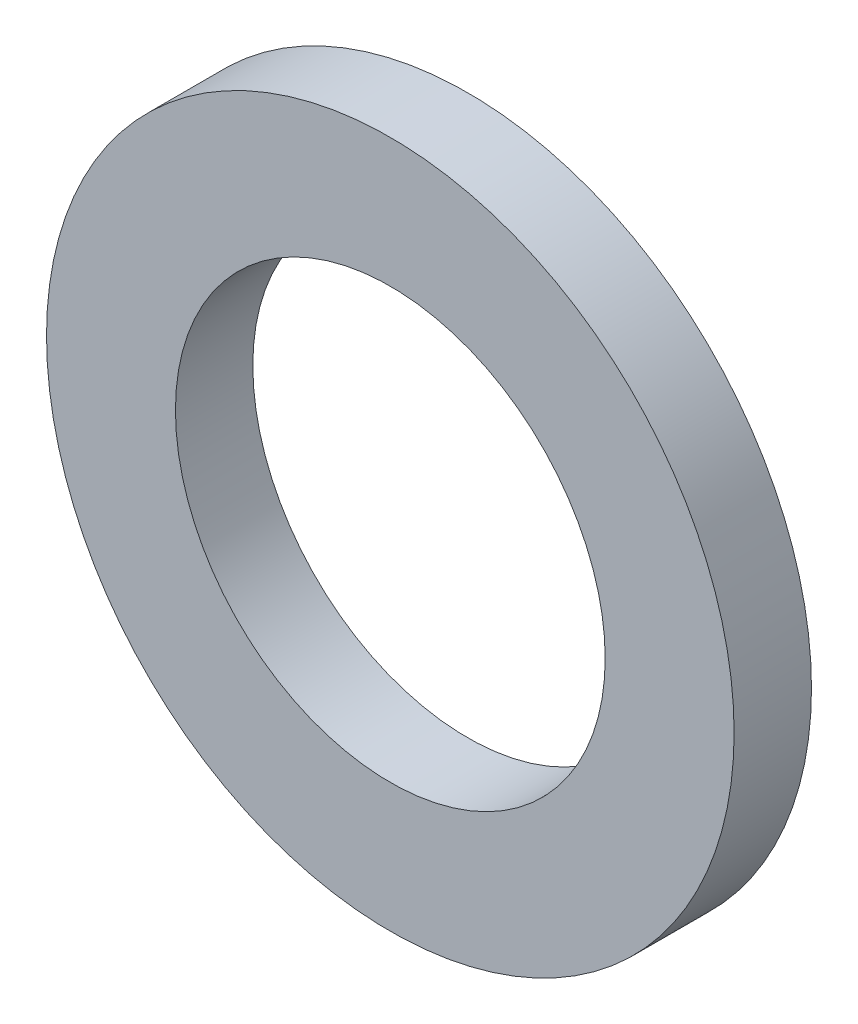
from build123d import *

# Parameters (mm, degrees)
SKETCH3_R                = 12
SKETCH3_R_2              = 7.5
BOSS_EXTRUDE1_DEPTH      = 1.35
BOSS_EXTRUDE1_DEPTH_BACK = 1.35


with BuildPart() as part:
    # Sketch3 → Boss-Extrude1 (new body, two sides)
    with BuildSketch(Plane.XY) as boss_extrude1_sk:
        Circle(SKETCH3_R)
        Circle(SKETCH3_R_2, mode=Mode.SUBTRACT)
    extrude(amount=BOSS_EXTRUDE1_DEPTH)
    extrude(boss_extrude1_sk.sketch, amount=-BOSS_EXTRUDE1_DEPTH_BACK)


solid = part.part
